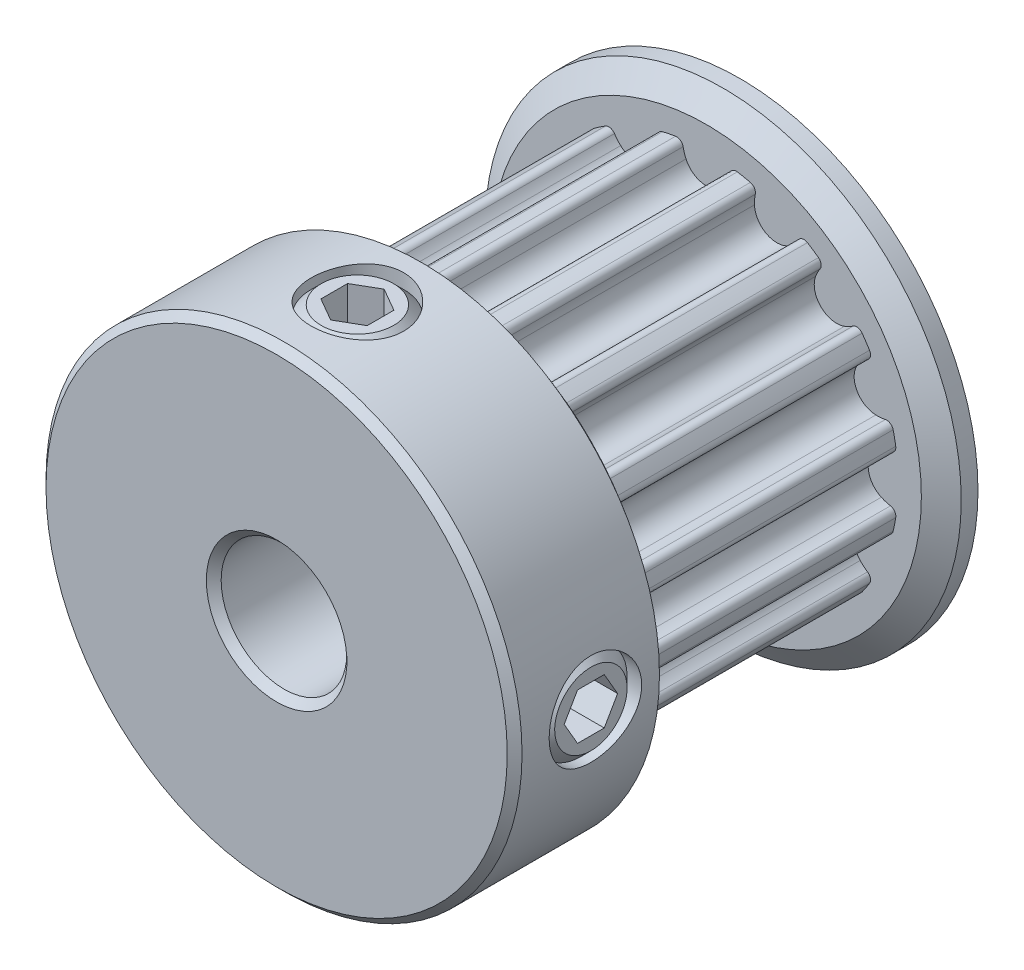
from build123d import *

# Parameters (mm, degrees)
CUT_EXTRUDE1_START = 2.655
CUT_EXTRUDE1_DEPTH = 10.16
CIRPATTERN1_COUNT  = 16
SKETCH4_R          = 1.7526
CUT_EXTRUDE2_DEPTH = 16.477114557
CUT_EXTRUDE3_DEPTH = 1.31445
CIRPATTERN3_COUNT  = 2
CIRPATTERN3_ANGLE  = 90
CHAMFER1_SIZE      = 0.28075


with BuildPart() as part:
    # Sketch2 → Revolve1 (revolve)
    with BuildSketch(Plane(origin=(0, 0, 0), x_dir=(0, 0, -1), z_dir=(1, 0, 0)), mode=Mode.PRIVATE) as revolve1_sk:
        Polygon((-8.775, 2.38125), (8.775, 2.38125), (8.775, 9.015), (8.14, 9.015), (7.505, 8.13975), (7.505, 7.2645), (-2.655, 7.2645), (-2.655, 8.13975), (-3.29, 9.015), (-8.775, 9.015), align=None)
    revolve(revolve1_sk.sketch.rotate(Axis((0, 0, 8.775), (0, 0, -1)), 90), axis=Axis((0, 0, 8.775), (0, 0, -1)))

    # Sketch3 → Cut-Extrude1 (cut)
    with BuildSketch(Plane.XY.offset(CUT_EXTRUDE1_START)):
        with BuildLine():
            Line((3.757926927, 9.015), (-3.757926927, 9.015))
            Line((-3.757926927, 9.015), (-2.795101196, 6.705249403))
            ThreePointArc((-2.795101196, 6.705249403), (-1.995846132, 6.984952288), (-1.169472895, 7.169748489))
            ThreePointArc((-1.169472895, 7.169748489), (-0.985767742, 7.127751824), (-0.883573242, 6.969424355))
            ThreePointArc((-0.883573242, 6.969424355), (-0.839120956, 6.792881518), (-0.773880597, 6.622919538))
            ThreePointArc((-0.773880597, 6.622919538), (0, 6.1245), (0.773880597, 6.622919538))
            ThreePointArc((0.773880597, 6.622919538), (0.839120956, 6.792881518), (0.883573242, 6.969424355))
            ThreePointArc((0.883573242, 6.969424355), (0.985767742, 7.127751824), (1.169472895, 7.169748489))
            ThreePointArc((1.169472895, 7.169748489), (1.995846132, 6.984952288), (2.795101196, 6.705249403))
            Line((2.795101196, 6.705249403), (3.757926927, 9.015))
        make_face()
    cut_extrude1 = extrude(amount=-CUT_EXTRUDE1_DEPTH, mode=Mode.SUBTRACT)

    # CirPattern1: Cut-Extrude1 ×16 about axis
    cirpattern1_axis = Axis((0, 0, 0), (0, 0, 1))
    for i in range(1, CIRPATTERN1_COUNT):
        add(cut_extrude1.rotate(cirpattern1_axis, i * 360 / CIRPATTERN1_COUNT), mode=Mode.SUBTRACT)

    # Sketch4 → Cut-Extrude2 (cut, through all)
    with BuildSketch(Plane(origin=(0, 0, 0), x_dir=(0, -1, 0), z_dir=(1, 0, 0))):
        with Locations(Location((0, -5.715, 0), (0, 0, 270))):
            Circle(SKETCH4_R)
    cut_extrude2 = extrude(amount=CUT_EXTRUDE2_DEPTH, mode=Mode.SUBTRACT)

    # Sketch5 → Revolve2 (revolve)
    with BuildSketch(Plane.XY.offset(5.715), mode=Mode.PRIVATE) as revolve2_sk:
        Polygon((2.38125, -1.3716), (2.38125, 0), (8.842998261, 0), (8.842998261, -1.3716), (8.461998261, -1.7526), (2.76225, -1.7526), align=None)
    revolve2 = revolve(revolve2_sk.sketch.rotate(Axis((2.38125, 0, 5.715), (1, 0, 0)), 270), axis=Axis((2.38125, 0, 5.715), (1, 0, 0)))

    # Sketch6 → Cut-Extrude3 (cut)
    with BuildSketch(Plane(origin=(8.842998261, 5.384140679, 0), x_dir=(0, -1, 0), z_dir=(-1, 0, 0))):
        Polygon((5.384140679, 6.726864082), (4.507840679, 6.220932041), (4.507840679, 5.209067959), (5.384140679, 4.703135918), (6.260440679, 5.209067959), (6.260440679, 6.220932041), align=None)
    cut_extrude3 = extrude(amount=CUT_EXTRUDE3_DEPTH, mode=Mode.SUBTRACT)

    # CirPattern3: Cut-Extrude2, Revolve2, Cut-Extrude3 ×2 about axis
    cirpattern3_axis = Axis((0, 0, 0), (0, 0, 1))
    add([cut_extrude2.rotate(cirpattern3_axis, i * CIRPATTERN3_ANGLE / (CIRPATTERN3_COUNT - 1)) for i in range(1, CIRPATTERN3_COUNT)], mode=Mode.SUBTRACT)
    add([revolve2.rotate(cirpattern3_axis, i * CIRPATTERN3_ANGLE / (CIRPATTERN3_COUNT - 1)) for i in range(1, CIRPATTERN3_COUNT)])
    add([cut_extrude3.rotate(cirpattern3_axis, i * CIRPATTERN3_ANGLE / (CIRPATTERN3_COUNT - 1)) for i in range(1, CIRPATTERN3_COUNT)], mode=Mode.SUBTRACT)

    # Chamfer1
    chamfer1_edges = [part.edges().sort_by_distance(p)[0] for p in [
        (-2.38125, 0, 8.775),
        (-9.015, 0, 8.775),
    ]]
    chamfer(chamfer1_edges, length=CHAMFER1_SIZE)


solid = part.part
